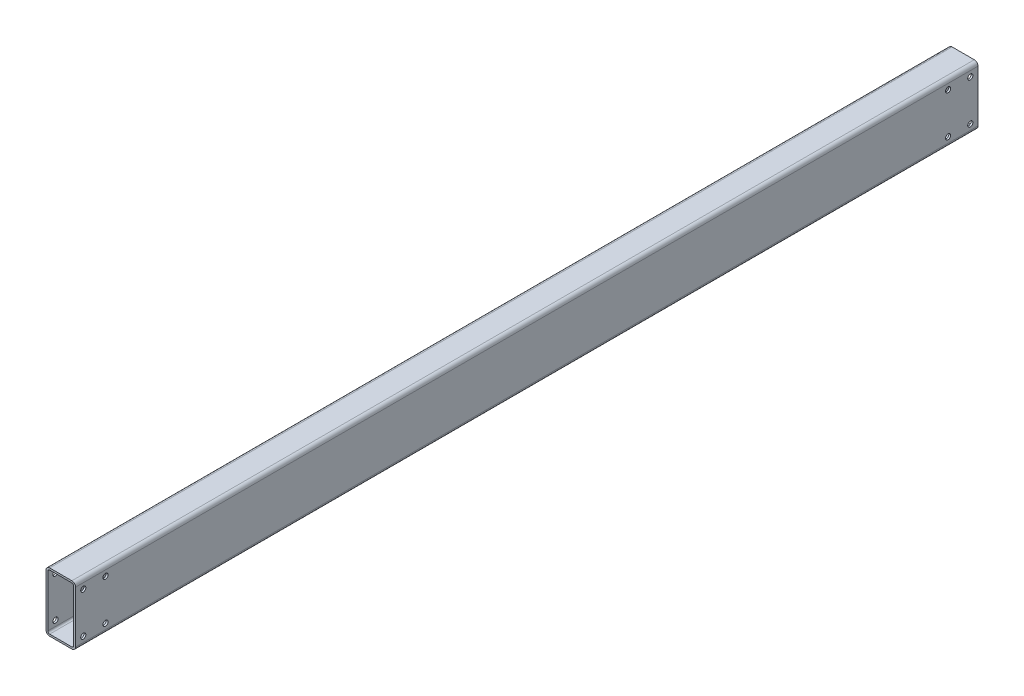
from build123d import *

# Parameters (mm, degrees)
BOSS_EXTRUDE1_DEPTH = 1220
SKETCH2_R           = 3.5
CUT_EXTRUDE1_DEPTH  = 41


with BuildPart() as part:
    # Sketch1 → Boss-Extrude1 (new body)
    with BuildSketch(Plane.XY):
        with BuildLine():
            Line((-15, -40), (15, -40))
            ThreePointArc((15, -40), (18.535533906, -38.535533906), (20, -35))
            Line((20, -35), (20, 35))
            ThreePointArc((20, 35), (18.535533906, 38.535533906), (15, 40))
            Line((15, 40), (-15, 40))
            ThreePointArc((-15, 40), (-18.535533906, 38.535533906), (-20, 35))
            Line((-20, 35), (-20, -35))
            ThreePointArc((-20, -35), (-18.535533906, -38.535533906), (-15, -40))
        make_face()
        with BuildLine():
            Line((-17.5, -35), (-17.5, 35))
            ThreePointArc((-17.5, 35), (-16.767766953, 36.767766953), (-15, 37.5))
            Line((-15, 37.5), (15, 37.5))
            ThreePointArc((15, 37.5), (16.767766953, 36.767766953), (17.5, 35))
            Line((17.5, 35), (17.5, -35))
            ThreePointArc((17.5, -35), (16.767766953, -36.767766953), (15, -37.5))
            Line((15, -37.5), (-15, -37.5))
            ThreePointArc((-15, -37.5), (-16.767766953, -36.767766953), (-17.5, -35))
        make_face(mode=Mode.SUBTRACT)
    extrude(amount=BOSS_EXTRUDE1_DEPTH)

    # Sketch2 → Cut-Extrude1 (cut, through all)
    with BuildSketch(Plane.ZY.offset(20)):
        with Locations((10.4, 27.5)):
            Circle(SKETCH2_R)
        with Locations((40.4, 27.5)):
            Circle(SKETCH2_R)
        with Locations((40.4, -27.5)):
            Circle(SKETCH2_R)
        with Locations((10.4, -27.5)):
            Circle(SKETCH2_R)
    cut_extrude1 = extrude(amount=-CUT_EXTRUDE1_DEPTH, mode=Mode.SUBTRACT)

    # Mirror1: Cut-Extrude1 across plane
    add(cut_extrude1.mirror(Plane.XY.offset(610)), mode=Mode.SUBTRACT)


solid = part.part
